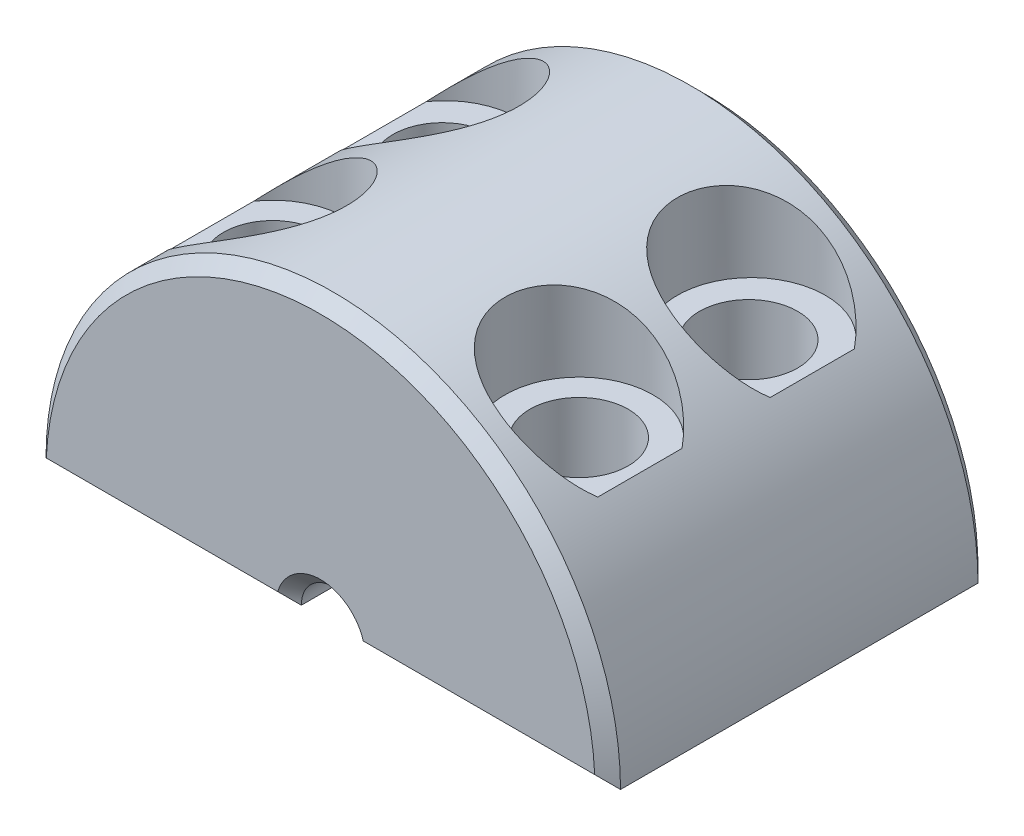
from build123d import *

# Parameters (mm, degrees)
BOSS_EXTRUDE2_DEPTH = 15.24
CHAMFER1_SIZE       = 0.508
SKETCH4_R           = 2.9464
SKETCH4_R_2         = 1.9558
CUT_EXTRUDE1_DEPTH  = 3.81
SKETCH6_R           = 1.9558
CUT_EXTRUDE2_DEPTH  = 12.4300001


with BuildPart() as part:
    # Sketch2 → Boss-Extrude2 (new body)
    with BuildSketch(Plane.XY):
        with BuildLine():
            Line((-11.43, 0), (-1.27, 0))
            ThreePointArc((-1.27, 0), (0, 1.27), (1.27, 0))
            Line((1.27, 0), (11.43, 0))
            ThreePointArc((11.43, 0), (0, 11.43), (-11.43, 0))
        make_face()
    extrude(amount=BOSS_EXTRUDE2_DEPTH)

    # Chamfer1
    chamfer1_edges = [part.edges().sort_by_distance(p)[0] for p in [
        (0, 11.43, 15.24),
        (-6.35, 0, 15.24),
        (0, 1.27, 15.24),
        (-6.35, 0, 0),
        (0, 11.43, 0),
        (6.35, 0, 0),
        (0, 1.27, 0),
        (6.35, 0, 15.24),
    ]]
    chamfer(chamfer1_edges, length=CHAMFER1_SIZE)

    # Sketch4 → Cut-Extrude1 (cut)
    with BuildSketch(Plane(origin=(0, 11.43, 0), x_dir=(1, 0, 0), z_dir=(0, 1, 0))):
        with Locations((-6.096, -4.191)):
            Circle(SKETCH4_R)
        with Locations((-6.096, -4.303195449)):
            Circle(SKETCH4_R_2, mode=Mode.SUBTRACT)
        with Locations((-6.096, -11.049)):
            Circle(SKETCH4_R)
        with Locations((-6.096, -11.049)):
            Circle(SKETCH4_R_2, mode=Mode.SUBTRACT)
        with Locations((6.096, -4.191)):
            Circle(SKETCH4_R)
        with Locations((6.096, -4.303195449)):
            Circle(SKETCH4_R_2, mode=Mode.SUBTRACT)
        with Locations((6.096, -11.049)):
            Circle(SKETCH4_R)
        with Locations((6.096, -11.049)):
            Circle(SKETCH4_R_2, mode=Mode.SUBTRACT)
    extrude(amount=-CUT_EXTRUDE1_DEPTH, mode=Mode.SUBTRACT)

    # Sketch6 → Cut-Extrude2 (cut, through all)
    with BuildSketch(Plane(origin=(0, 11.43, 0), x_dir=(1, 0, 0), z_dir=(0, 1, 0))):
        with Locations((-6.096, -4.303195449)):
            Circle(SKETCH6_R)
        with Locations((-6.096, -11.049)):
            Circle(SKETCH6_R)
        with Locations((6.096, -11.049)):
            Circle(SKETCH6_R)
        with Locations((6.096, -4.303195449)):
            Circle(SKETCH6_R)
    extrude(amount=-CUT_EXTRUDE2_DEPTH, mode=Mode.SUBTRACT)


solid = part.part
